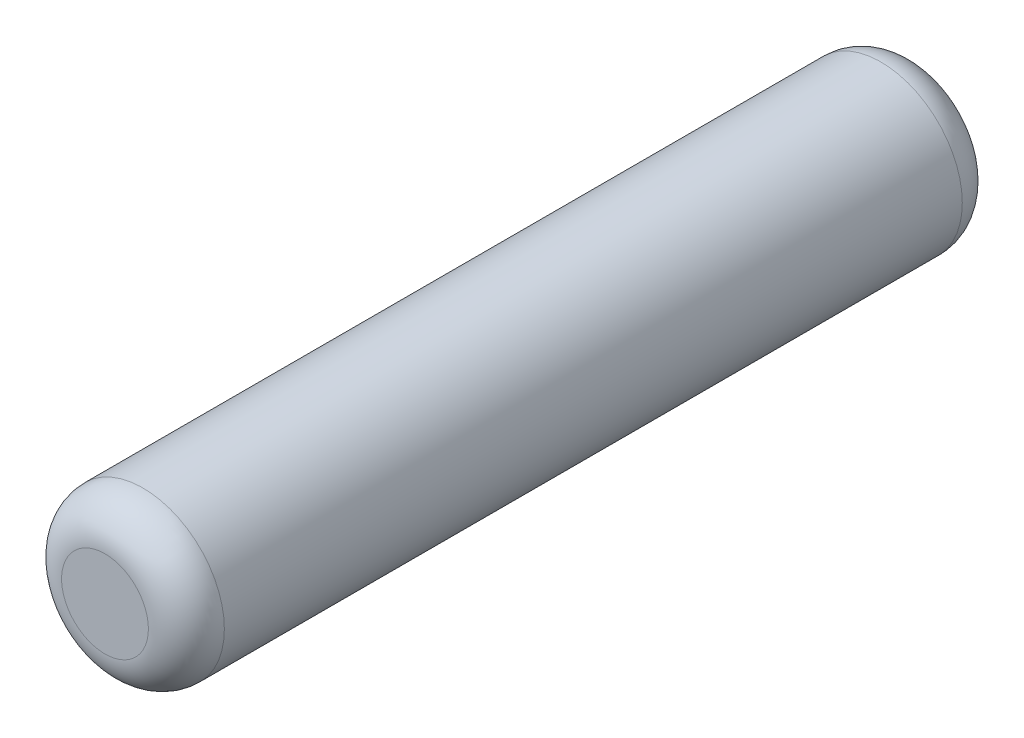
from build123d import *

# Parameters (mm, degrees)
SKETCH1_R           = 0.75
BOSS_EXTRUDE1_DEPTH = 3.75
FILLET1_R           = 0.35


with BuildPart() as part:
    # Sketch1 → Boss-Extrude1 (new body, symmetric)
    with BuildSketch(Plane.XY):
        Circle(SKETCH1_R)
    extrude(amount=BOSS_EXTRUDE1_DEPTH, both=True)

    # Fillet1
    fillet1_edges = [part.edges().sort_by_distance(p)[0] for p in [
        (-0.75, 0, -3.75),
        (-0.75, 0, 3.75),
    ]]
    fillet(fillet1_edges, radius=FILLET1_R)


solid = part.part
